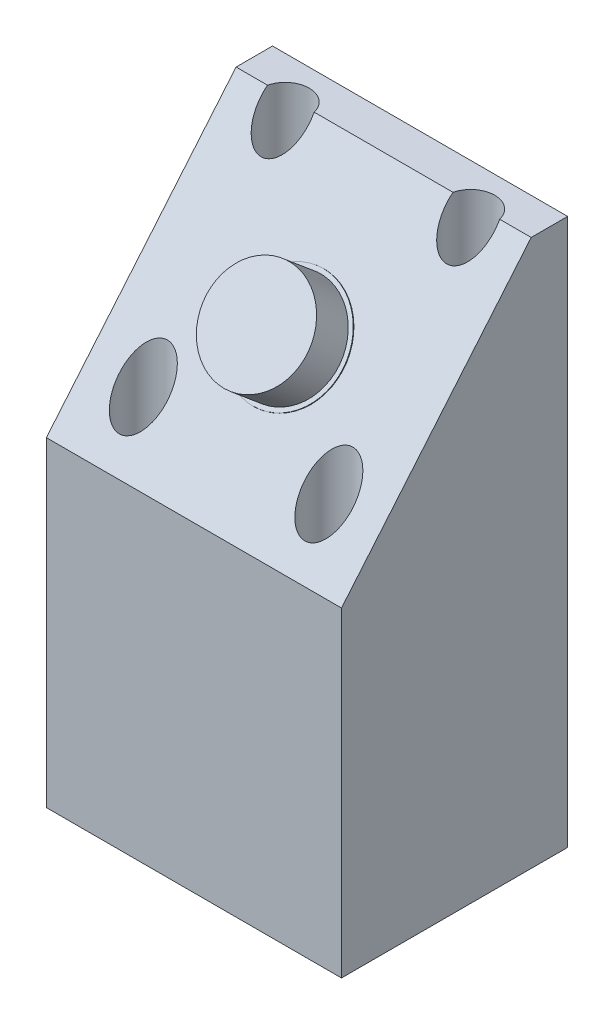
from build123d import *

# Parameters (mm, degrees)
AUFSATZ_LINEAR_AUSTRAGEN1_DEPTH      = 35
SKIZZE3_R                            = 6
AUFSATZ_LINEAR_AUSTRAGEN2_DEPTH      = 5
SKIZZE4_R                            = 6.5
AUFSATZ_LINEAR_AUSTRAGEN3_DEPTH      = 0.1
SKIZZE7_R                            = 2.85
SCHNITT_LINEAR_AUSTRAGEN1_DEPTH      = 61.311555509
F_3_4_3_4_DURCHMESSER_BOHRUNG1_D     = 3.4
F_3_4_3_4_DURCHMESSER_BOHRUNG1_DEPTH = 4.5


with BuildPart() as part:
    # Skizze1 → Aufsatz-Linear austragen1 (new body)
    with BuildSketch(Plane(origin=(0, 0, 0), x_dir=(0, 0, -1), z_dir=(1, 0, 0))):
        Polygon((0, 0), (22.497566339, 0), (26.82, 0), (26.82, 64.811555509), (22.497566339, 64.811555509), (0, 38), align=None)
    extrude(amount=AUFSATZ_LINEAR_AUSTRAGEN1_DEPTH)

    # Skizze3 → Aufsatz-Linear austragen2 (add)
    with BuildSketch(Plane(origin=(0, 15.700684624, 18.711347307), x_dir=(1, 0, 0), z_dir=(0, 0.64278761, 0.766044443))):
        with Locations((17.5, 46.609688839)):
            Circle(SKIZZE3_R)
    extrude(amount=AUFSATZ_LINEAR_AUSTRAGEN2_DEPTH)

    # Skizze4 → Aufsatz-Linear austragen3 (add)
    with BuildSketch(Plane(origin=(0, 15.700684624, 18.711347307), x_dir=(1, 0, 0), z_dir=(0, 0.64278761, 0.766044443))):
        with Locations((17.5, 46.609688839)):
            Circle(SKIZZE4_R)
    extrude(amount=AUFSATZ_LINEAR_AUSTRAGEN3_DEPTH)

    # Skizze7 → Schnitt-Linear austragen1 (cut, through all)
    with BuildSketch(Plane(origin=(0, 4.5, 0), x_dir=(-1, 0, 0), z_dir=(0, -1, 0))):
        with Locations((-28.5, 5)):
            Circle(SKIZZE7_R)
        with Locations((-6.5, 5)):
            Circle(SKIZZE7_R)
        with Locations((-6.5, 21.82)):
            Circle(SKIZZE7_R)
        with Locations((-28.5, 21.82)):
            Circle(SKIZZE7_R)
    extrude(amount=-SCHNITT_LINEAR_AUSTRAGEN1_DEPTH, mode=Mode.SUBTRACT)

    # Ø3.4 (3.4) Durchmesser Bohrung1
    with Locations(Plane(origin=(6.5, 4.5, -5), x_dir=(0, 0, 1), z_dir=(0, 1, 0))):
        with Locations((0, 0), (-16.82, 0), (-16.82, 22), (0, 22)):
            Hole(F_3_4_3_4_DURCHMESSER_BOHRUNG1_D / 2, depth=F_3_4_3_4_DURCHMESSER_BOHRUNG1_DEPTH)


solid = part.part
